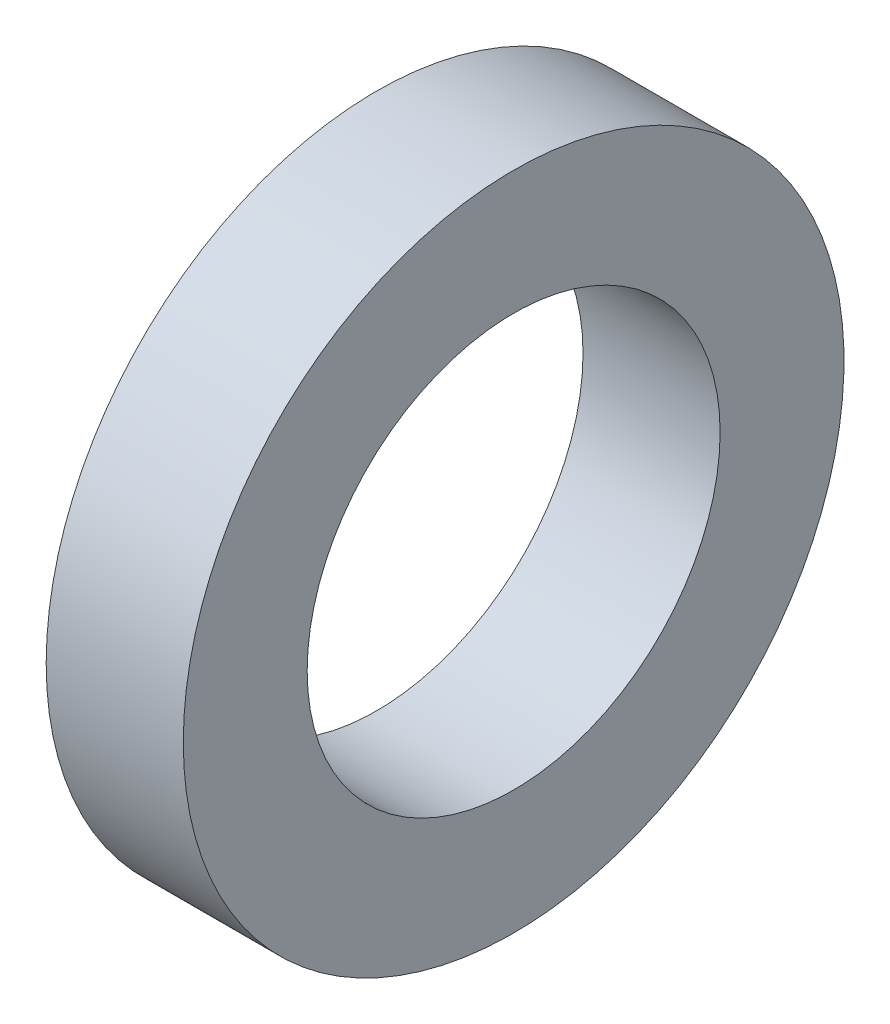
from build123d import *

# Parameters (mm, degrees)
SKETCH3_W = 4.979999946
SKETCH3_H = 4.500000017


with BuildPart() as part:
    # Sketch3 → Revolve1 (revolve)
    with BuildSketch(Plane.XY):
        with Locations((20.529799809, 9.749999995)):
            Rectangle(SKETCH3_W, SKETCH3_H)
    revolve(axis=Axis((0, 0, 0), (1, 0, 0)))


solid = part.part
